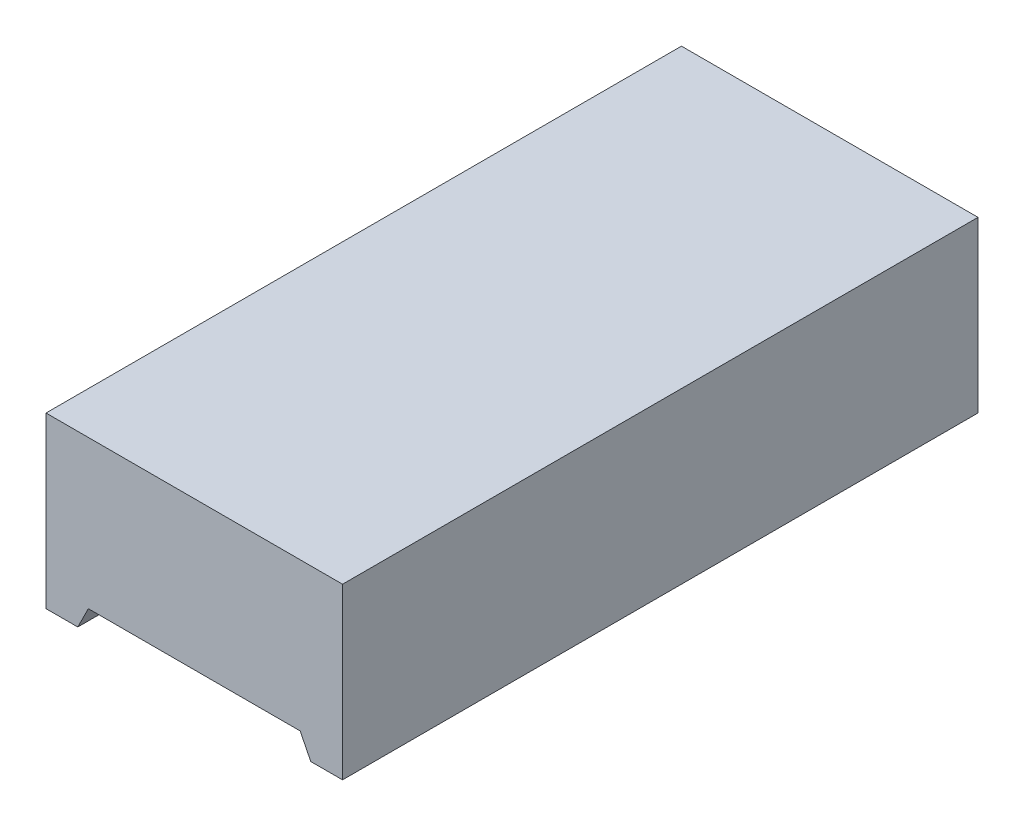
from build123d import *

# Parameters (mm, degrees)
BOSS_EXTRU_1_DEPTH = 15


with BuildPart() as part:
    # Esquisse1 → Boss.-Extru.1 (new body, symmetric)
    with BuildSketch(Plane.XY):
        Polygon((7, 0), (7, 8), (-7, 8), (-7, 0), (-5.5, 0), (-5, 1), (5, 1), (5.5, 0), align=None)
    extrude(amount=BOSS_EXTRU_1_DEPTH, both=True)


solid = part.part
